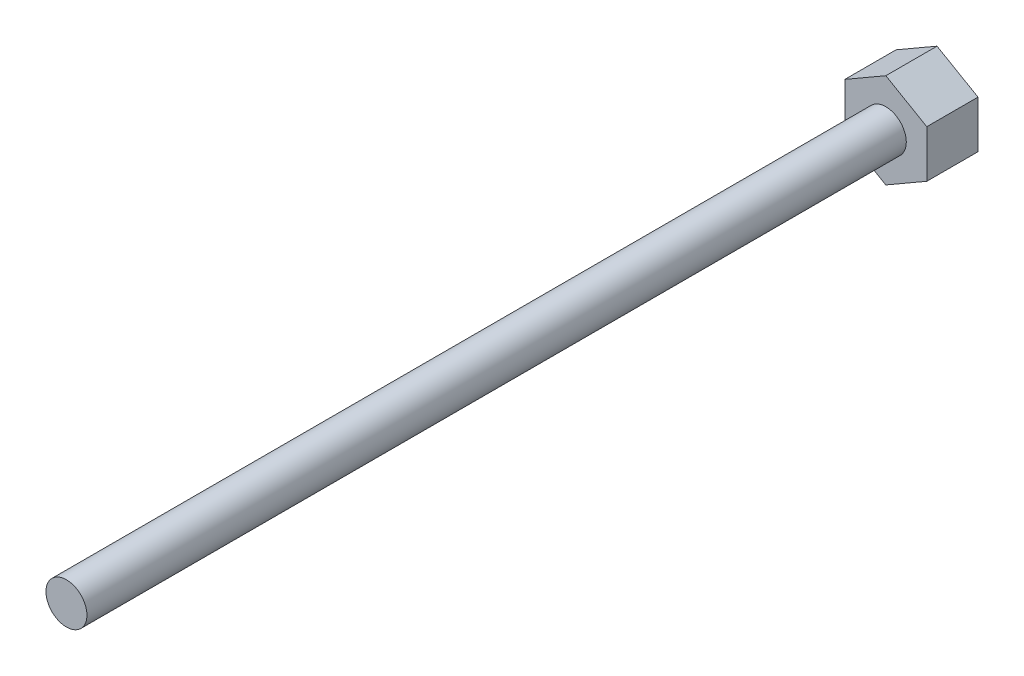
from build123d import *

# Parameters (mm, degrees)
SKETCH1_R           = 2
BOSS_EXTRUDE1_DEPTH = 80
BOSS_EXTRUDE2_DEPTH = 5


with BuildPart() as part:
    # Sketch1 → Boss-Extrude1 (new body)
    with BuildSketch(Plane.XY):
        Circle(SKETCH1_R)
    extrude(amount=BOSS_EXTRUDE1_DEPTH)

    # Sketch2 → Boss-Extrude2 (add)
    with BuildSketch(Plane(origin=(0, 0, 0), x_dir=(-1, 0, 0), z_dir=(0, 0, -1))):
        Polygon((0, 4.618802154), (-4, 2.309401077), (-4, -2.309401077), (0, -4.618802154), (4, -2.309401077), (4, 2.309401077), align=None)
    extrude(amount=BOSS_EXTRUDE2_DEPTH)


solid = part.part
